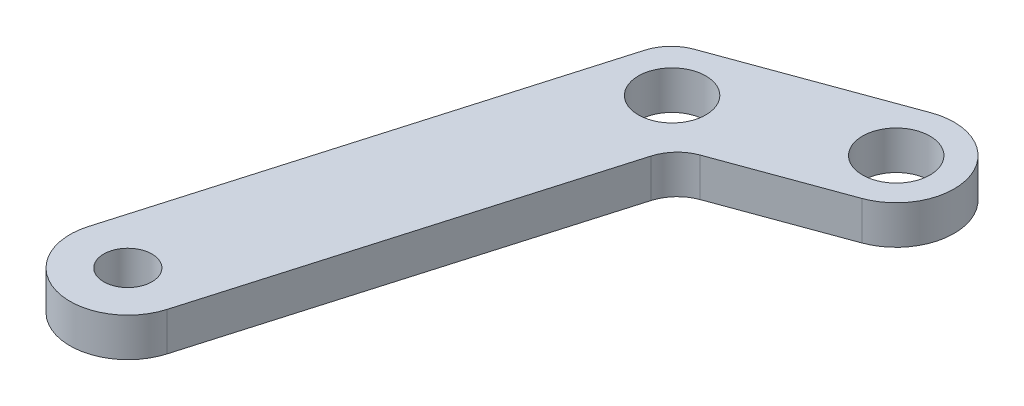
from build123d import *

# Parameters (mm, degrees)
SKETCH1_R           = 1.75
SKETCH1_R_2         = 1.25
BOSS_EXTRUDE1_DEPTH = 2
FILLET1_R           = 2


with BuildPart() as part:
    # Sketch1 → Boss-Extrude1 (new body)
    with BuildSketch(Plane(origin=(0, 0, 0), x_dir=(1, 0, 0), z_dir=(0, 1, 0))):
        with BuildLine():
            Line((-10609.380855774, 26644.275372767), (-10602.594176906, 26667.581570052))
            Line((-10602.594176906, 26667.581570052), (-10592.660823342, 26671.213057009))
            ThreePointArc((-10592.660823342, 26671.213057009), (-10588.813133366, 26669.425521878), (-10590.600668497, 26665.577831901))
            Line((-10590.600668497, 26665.577831901), (-10597.682341811, 26662.988877013))
            Line((-10597.682341811, 26662.988877013), (-10603.62012799, 26642.597870039))
            ThreePointArc((-10603.62012799, 26642.597870039), (-10607.339243246, 26640.556257511), (-10609.380855774, 26644.275372767))
        make_face()
        with Locations((-10591.63074592, 26668.395444455)):
            Circle(SKETCH1_R, mode=Mode.SUBTRACT)
        with Locations((-10600.138259358, 26665.285223533)):
            Circle(SKETCH1_R, mode=Mode.SUBTRACT)
        with Locations((-10606.500491882, 26643.436621403)):
            Circle(SKETCH1_R_2, mode=Mode.SUBTRACT)
    extrude(amount=BOSS_EXTRUDE1_DEPTH)

    # Fillet1
    fillet1_edges = [part.edges().sort_by_distance(p)[0] for p in [
        (-10597.682341811, 1, -26662.988877013),
        (-10602.594176906, 1, -26667.581570052),
    ]]
    fillet(fillet1_edges, radius=FILLET1_R)


solid = part.part
